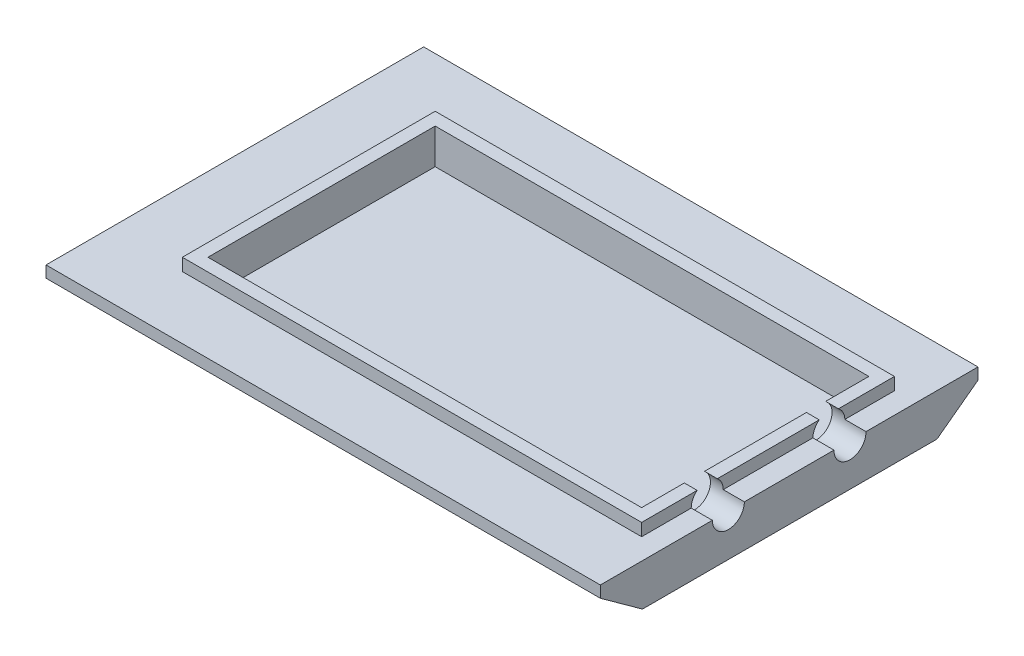
from build123d import *

# Parameters (mm, degrees)
SKETCH2_2_W         = 219.964
SKETCH2_2_H         = 149.86
BOSS_EXTRUDE2_DEPTH = 4.572
SKETCH3_W           = 182.245
SKETCH3_H           = 100.33
BOSS_EXTRUDE3_DEPTH = 5.08
SKETCH4_W           = 172.085
SKETCH4_H           = 90.17
CUT_EXTRUDE1_DEPTH  = 258.8719036
SKETCH4_2_W         = 172.085
SKETCH4_2_H         = 90.17
CUT_EXTRUDE2_DEPTH  = 8.89
SKETCH5_R           = 6.35
CUT_EXTRUDE3_DEPTH  = 19.05


with BuildPart() as part:
    # Sketch2 → Loft1 section 0
    with BuildSketch(Plane(origin=(0, 12.0904, 0), x_dir=(1, 0, 0), z_dir=(0, 1, 0))):
        with BuildLine():
            Line((-219.964, 16.289130435), (0, 16.289130435))
            Line((0, 16.289130435), (0, -133.570869565))
            Line((0, -133.570869565), (-219.964, -133.570869565))
            Line((-219.964, -133.570869565), (-219.964, 16.289130435))
        make_face()
    # Sketch1 → Loft1 section 1
    with BuildSketch(Plane(origin=(0, 0, 0), x_dir=(1, 0, 0), z_dir=(0, 1, 0))):
        with BuildLine():
            Line((-190.5, 0), (0, 0))
            Line((0, 0), (0, -116.84))
            Line((0, -116.84), (-190.5, -116.84))
            Line((-190.5, -116.84), (-190.5, 0))
        make_face()
    loft()

    # Sketch2_2 → Boss-Extrude2 (add)
    with BuildSketch(Plane(origin=(0, 12.0904, 0), x_dir=(1, 0, 0), z_dir=(0, 1, 0))):
        with Locations((-109.982, -58.640869565)):
            Rectangle(SKETCH2_2_W, SKETCH2_2_H)
    extrude(amount=BOSS_EXTRUDE2_DEPTH)

    # Sketch3 → Boss-Extrude3 (add)
    with BuildSketch(Plane(origin=(0, 16.51, 0), x_dir=(1, 0, 0), z_dir=(0, 1, 0))):
        with Locations((-99.5045, -58.640869565)):
            Rectangle(SKETCH3_W, SKETCH3_H)
    extrude(amount=BOSS_EXTRUDE3_DEPTH)

    # Sketch4 → Cut-Extrude1 (cut, through all)
    with BuildSketch(Plane(origin=(0, 16.51, 0), x_dir=(1, 0, 0), z_dir=(0, 1, 0))):
        with Locations((-99.5045, -58.640869565)):
            Rectangle(SKETCH4_W, SKETCH4_H)
    extrude(amount=CUT_EXTRUDE1_DEPTH, mode=Mode.SUBTRACT)

    # Sketch4_2 → Cut-Extrude2 (cut)
    with BuildSketch(Plane(origin=(0, 16.51, 0), x_dir=(1, 0, 0), z_dir=(0, 1, 0))):
        with Locations((-99.5045, -58.640869565)):
            Rectangle(SKETCH4_2_W, SKETCH4_2_H)
    extrude(amount=-CUT_EXTRUDE2_DEPTH, mode=Mode.SUBTRACT)

    # Sketch5 → Cut-Extrude3 (cut)
    with BuildSketch(Plane(origin=(0, 0, 0), x_dir=(0, 0, -1), z_dir=(1, 0, 0))):
        with Locations((-82.770869565, 16.6624)):
            Circle(SKETCH5_R)
        with Locations((-34.510869565, 16.51)):
            Circle(SKETCH5_R)
    extrude(amount=-CUT_EXTRUDE3_DEPTH, mode=Mode.SUBTRACT)


solid = part.part
